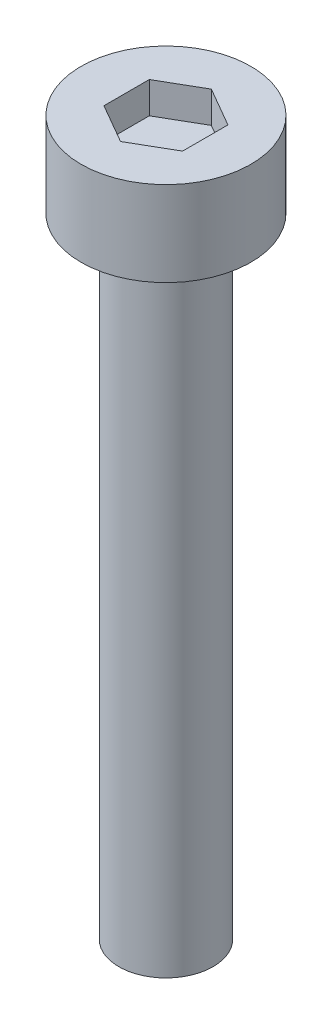
from build123d import *

# Parameters (mm, degrees)
SKETCH1_R           = 2.7
BOSS_EXTRUDE1_DEPTH = 2.7
CUT_EXTRUDE1_DEPTH  = 1
SKETCH3_R           = 1.5
BOSS_EXTRUDE2_DEPTH = 20


with BuildPart() as part:
    # Sketch1 → Boss-Extrude1 (new body)
    with BuildSketch(Plane(origin=(0, 0, 0), x_dir=(1, 0, 0), z_dir=(0, 1, 0))):
        Circle(SKETCH1_R)
    extrude(amount=BOSS_EXTRUDE1_DEPTH)

    # Sketch2 → Cut-Extrude1 (cut)
    with BuildSketch(Plane(origin=(0, 2.7, 0), x_dir=(1, 0, 0), z_dir=(0, 1, 0))):
        Polygon((0, 1.443375673), (-1.25, 0.721687836), (-1.25, -0.721687836), (0, -1.443375673), (1.25, -0.721687836), (1.25, 0.721687836), align=None)
    extrude(amount=-CUT_EXTRUDE1_DEPTH, mode=Mode.SUBTRACT)

    # Sketch3 → Boss-Extrude2 (add)
    with BuildSketch(Plane.XZ):
        Circle(SKETCH3_R)
    extrude(amount=BOSS_EXTRUDE2_DEPTH)


solid = part.part
